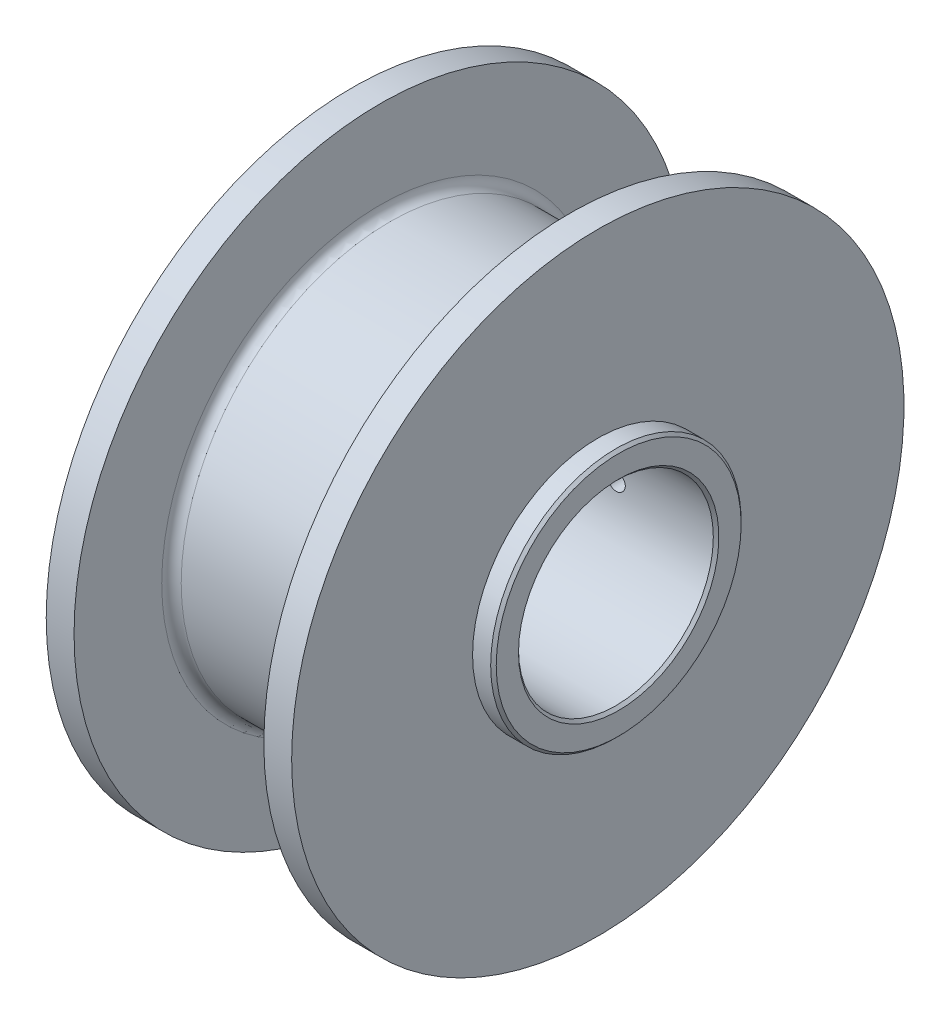
from build123d import *

# Parameters (mm, degrees)
SKETCH3_W                         = 20.32
SKETCH3_H                         = 50.8
CUT_EXTRUDE1_DEPTH                = 2.54
F_1_8_0_125_DIAMETER_HOLE1_REACH  = 123.254
F_1_8_0_125_DIAMETER_HOLE1_BORE_R = 1.5875
FILLET2_R                         = 1.778
CHAMFER1_SIZE                     = 0.508


with BuildPart() as part:
    # Sketch1 → Revolve1 (revolve)
    with BuildSketch(Plane.XY, mode=Mode.PRIVATE) as revolve1_sk:
        Polygon((3.81, 55.88), (8.89, 55.88), (8.89, 38.1), (43.5280054, 38.1), (43.5280054, 55.88), (48.6080054, 55.88), (48.6080054, 22.86), (52.4180054, 22.86), (52.4180054, 17.78), (15.0800054, 17.78), (15.0800054, 16.002), (5.08, 16.002), (5.08, 11.079988), (0, 11.079988), (0, 22.86), (3.81, 22.86), align=None)
    revolve(revolve1_sk.sketch.rotate(Axis((0, 0, 0), (1, 0, 0)), 90), axis=Axis((0, 0, 0), (1, 0, 0)))

    # Sketch3 → Cut-Extrude1 (cut)
    with BuildSketch(Plane(origin=(0, 0, -38.1), x_dir=(-1, 0, 0), z_dir=(0, 0, -1))):
        with Locations((-34.2570054, 0)):
            Rectangle(SKETCH3_W, SKETCH3_H)
    extrude(amount=-CUT_EXTRUDE1_DEPTH, mode=Mode.SUBTRACT)

    # 1/8 (0.125) Diameter Hole1 bore → 1/8 (0.125) Diameter Hole1 (cut, up to next)
    with BuildSketch(Plane(origin=(0, 0, -38.1), x_dir=(-1, 0, 0), z_dir=(0, 0, -1)), mode=Mode.PRIVATE) as f_1_8_0_125_diameter_hole1_sk1:
        with Locations((-34.2570054, 0)):
            Circle(F_1_8_0_125_DIAMETER_HOLE1_BORE_R)
    f_1_8_0_125_diameter_hole1_tool1 = extrude(f_1_8_0_125_diameter_hole1_sk1.sketch, amount=-F_1_8_0_125_DIAMETER_HOLE1_REACH, mode=Mode.PRIVATE) & part.part
    add(f_1_8_0_125_diameter_hole1_tool1.solids().sort_by_distance((34.257005, 0, -38.1))[0], mode=Mode.SUBTRACT)

    # Fillet2
    fillet2_edges = [part.edges().sort_by_distance(p)[0] for p in [
        (8.89, 0, -38.1),
        (43.5280054, 37.459618258, 6.95607648),
    ]]
    fillet(fillet2_edges, radius=FILLET2_R)

    # Chamfer1
    chamfer1_edges = [part.edges().sort_by_distance(p)[0] for p in [
        (0, 0, -22.86),
        (0, 0, -11.079988),
        (52.4180054, 0, -17.78),
        (52.4180054, 0, -22.86),
    ]]
    chamfer(chamfer1_edges, length=CHAMFER1_SIZE)


solid = part.part
